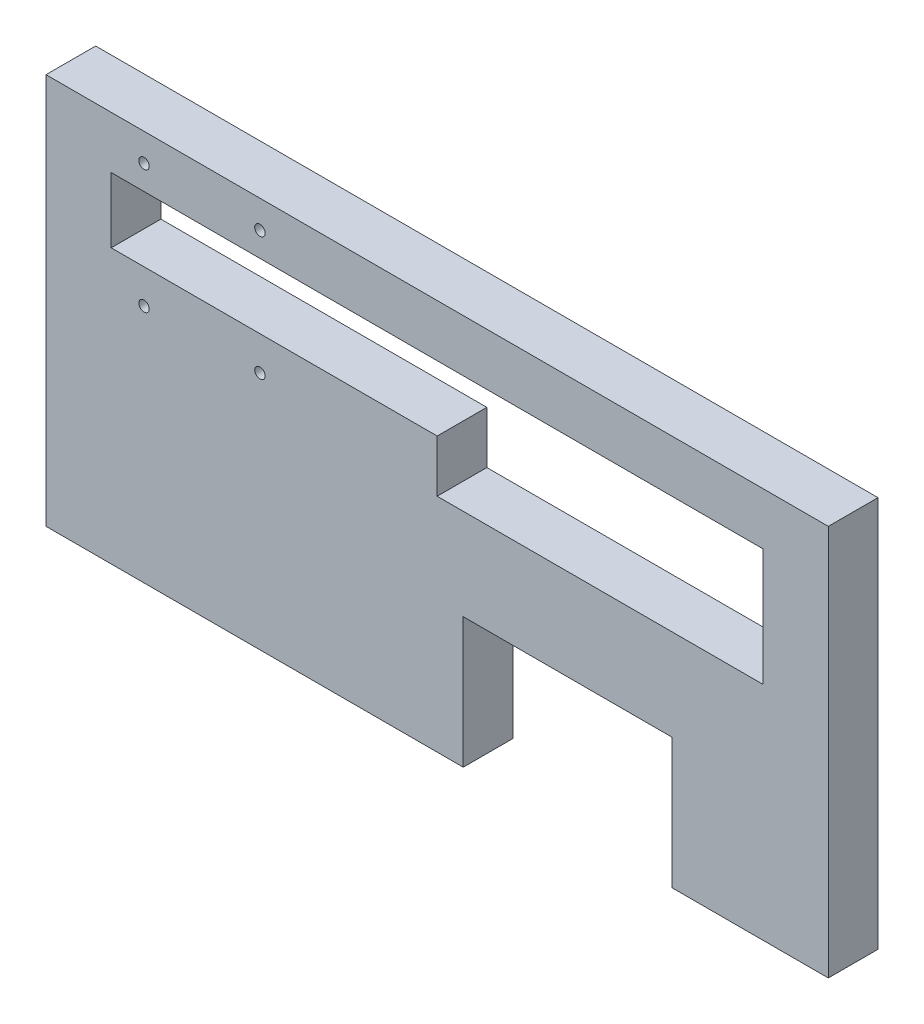
from build123d import *

# Parameters (mm, degrees)
SKETCH1_W          = 300
SKETCH1_H          = 150
BLOCK_DEPTH        = 19.05
SKETCH3_W          = 250
SKETCH3_H          = 25
CUT_EXTRUDE2_DEPTH = 39.961179
SKETCH6_W          = 125
SKETCH6_H          = 20
CUT_EXTRUDE5_DEPTH = 20.05
SKETCH7_W          = 80
SKETCH7_H          = 50
CUT_EXTRUDE6_DEPTH = 20.05
SKETCH8_R          = 2
CUT_EXTRUDE7_DEPTH = 20.05


with BuildPart() as part:
    # Sketch1 → block (new body)
    with BuildSketch(Plane.XY):
        with Locations((150, 75)):
            Rectangle(SKETCH1_W, SKETCH1_H)
    extrude(amount=-BLOCK_DEPTH)

    # Sketch3 → Cut-Extrude2 (cut)
    with BuildSketch(Plane.XY):
        with Locations((150, 117.5)):
            Rectangle(SKETCH3_W, SKETCH3_H)
    extrude(amount=-CUT_EXTRUDE2_DEPTH, mode=Mode.SUBTRACT)

    # Sketch6 → Cut-Extrude5 (cut, through all)
    with BuildSketch(Plane.XY):
        with Locations((212.5, 95)):
            Rectangle(SKETCH6_W, SKETCH6_H)
    extrude(amount=-CUT_EXTRUDE5_DEPTH, mode=Mode.SUBTRACT)

    # Sketch7 → Cut-Extrude6 (cut, through all)
    with BuildSketch(Plane.XY):
        with Locations((200, 25)):
            Rectangle(SKETCH7_W, SKETCH7_H)
    extrude(amount=-CUT_EXTRUDE6_DEPTH, mode=Mode.SUBTRACT)

    # Sketch8 → Cut-Extrude7 (cut, through all)
    with BuildSketch(Plane.XY):
        with Locations((37.5875, 139.35)):
            Circle(SKETCH8_R)
        with Locations((82.0375, 139.35)):
            Circle(SKETCH8_R)
        with Locations((37.5875, 91.95)):
            Circle(SKETCH8_R)
        with Locations((82.0375, 91.95)):
            Circle(SKETCH8_R)
    extrude(amount=-CUT_EXTRUDE7_DEPTH, mode=Mode.SUBTRACT)


solid = part.part
